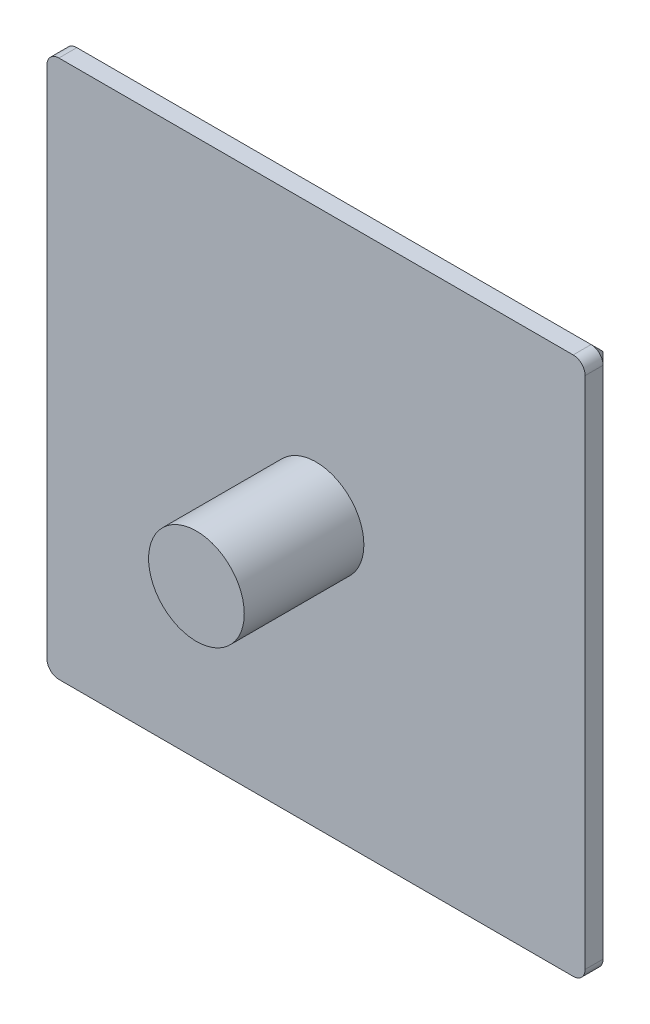
from build123d import *

# Parameters (mm, degrees)
SKETCH1_W           = 45
SKETCH1_H           = 45
BOSS_EXTRUDE1_DEPTH = 2.5
FILLET1_R           = 1
SKETCH2_R           = 4
BOSS_EXTRUDE2_DEPTH = 10
CHAMFER1_SIZE       = 1


with BuildPart() as part:
    # Sketch1 → Boss-Extrude1 (new body)
    with BuildSketch(Plane.XY):
        Rectangle(SKETCH1_W, SKETCH1_H)
    extrude(amount=BOSS_EXTRUDE1_DEPTH)

    # Fillet1
    fillet1_edges = [part.edges().sort_by_distance(p)[0] for p in [
        (-22.5, 22.5, 1.25),
        (22.5, 22.5, 1.25),
        (22.5, -22.5, 1.25),
        (-22.5, -22.5, 1.25),
    ]]
    fillet(fillet1_edges, radius=FILLET1_R)

    # Sketch2 → Boss-Extrude2 (add)
    with BuildSketch(Plane.XY.offset(2.5)):
        Circle(SKETCH2_R)
    extrude(amount=BOSS_EXTRUDE2_DEPTH)

    # Chamfer1
    chamfer1_edges = [part.edges().sort_by_distance(p)[0] for p in [
        (0, -22.5, 0),
        (-22.5, 0, 0),
        (0, 22.5, 0),
        (22.5, 0, 0),
        (22.207106781, 22.207106781, 0),
        (-22.207106781, 22.207106781, 0),
        (22.207106781, -22.207106781, 0),
        (-22.207106781, -22.207106781, 0),
    ]]
    chamfer(chamfer1_edges, length=CHAMFER1_SIZE)


solid = part.part
